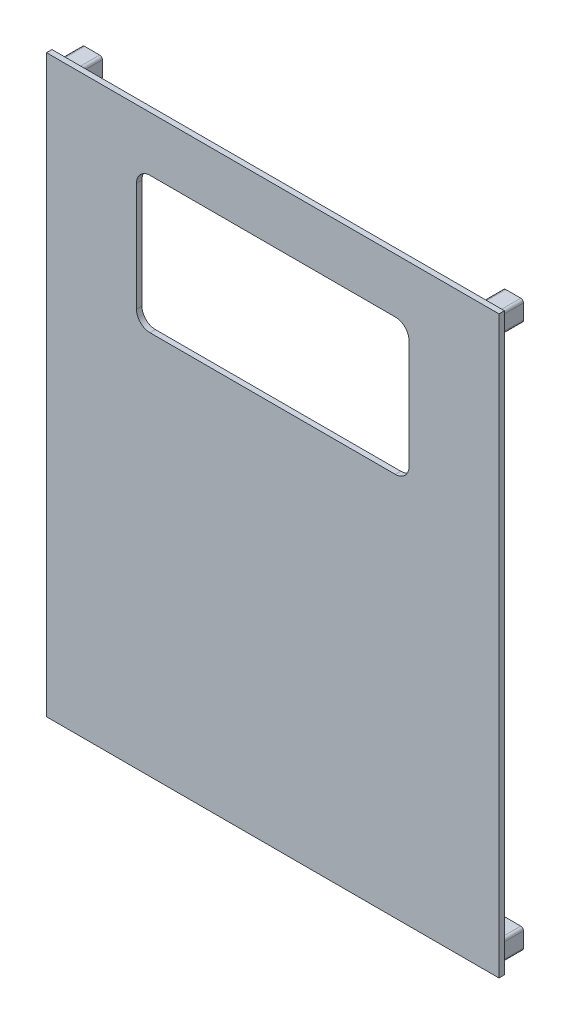
from build123d import *

# Parameters (mm, degrees)
BOSS_EXTRUDE1_DEPTH = 3
SKETCH2_W           = 166
SKETCH2_H           = 211.014567036
SKETCH2_W_2         = 100
SKETCH2_H_2         = 50
BOSS_EXTRUDE2_DEPTH = 3
CUT_EXTRUDE1_DEPTH  = 3
FILLET1_R           = 5
SKETCH4_W           = 7.5
SKETCH4_H           = 7.5
BOSS_EXTRUDE3_DEPTH = 11
FILLET2_R           = 1
SKETCH5_R           = 1.6
CUT_EXTRUDE2_DEPTH  = 5
SKETCH6_R           = 2.25
CUT_EXTRUDE3_DEPTH  = 3
SKETCH7_W           = 166
SKETCH7_H           = 211.014567036
CUT_EXTRUDE4_DEPTH  = 1


with BuildPart() as part:
    # Sketch1 → Boss-Extrude1 (new body)
    with BuildSketch(Plane.XY):
        with BuildLine():
            Line((48, 73.257283518), (48, -16.742716482))
            ThreePointArc((48, -16.742716482), (50.050252532, -21.69246395), (55, -23.742716482))
            Line((55, -23.742716482), (105, -23.742716482))
            ThreePointArc((105, -23.742716482), (109.949747468, -21.69246395), (112, -16.742716482))
            Line((112, -16.742716482), (112, 73.257283518))
            ThreePointArc((112, 73.257283518), (109.949747468, 78.207030987), (105, 80.257283518))
            Line((105, 80.257283518), (55, 80.257283518))
            ThreePointArc((55, 80.257283518), (50.050252532, 78.207030987), (48, 73.257283518))
        make_face()
        with BuildLine():
            Line((53, 73.257283518), (53, -16.742716482))
            ThreePointArc((53, -16.742716482), (53.585786438, -18.156930044), (55, -18.742716482))
            Line((55, -18.742716482), (105, -18.742716482))
            ThreePointArc((105, -18.742716482), (106.414213562, -18.156930044), (107, -16.742716482))
            Line((107, -16.742716482), (107, 73.257283518))
            ThreePointArc((107, 73.257283518), (106.414213562, 74.671497081), (105, 75.257283518))
            Line((105, 75.257283518), (55, 75.257283518))
            ThreePointArc((55, 75.257283518), (53.585786438, 74.671497081), (53, 73.257283518))
        make_face(mode=Mode.SUBTRACT)
    extrude(amount=-BOSS_EXTRUDE1_DEPTH)

    # Sketch2 → Boss-Extrude2 (add)
    with BuildSketch(Plane.XY):
        with Locations((80, -22.25)):
            Rectangle(SKETCH2_W, SKETCH2_H)
        with Locations((80, 38.257283518)):
            Rectangle(SKETCH2_W_2, SKETCH2_H_2, mode=Mode.SUBTRACT)
    extrude(amount=BOSS_EXTRUDE2_DEPTH)

    # Sketch3 → Cut-Extrude1 (cut)
    with BuildSketch(Plane(origin=(0, 0, -3), x_dir=(-1, 0, 0), z_dir=(0, 0, -1))):
        with BuildLine():
            Line((-55, 80.257283518), (-105, 80.257283518))
            ThreePointArc((-105, 80.257283518), (-109.949747468, 78.207030987), (-112, 73.257283518))
            Line((-112, 73.257283518), (-112, -16.742716482))
            ThreePointArc((-112, -16.742716482), (-109.949747468, -21.69246395), (-105, -23.742716482))
            Line((-105, -23.742716482), (-55, -23.742716482))
            ThreePointArc((-55, -23.742716482), (-50.050252532, -21.69246395), (-48, -16.742716482))
            Line((-48, -16.742716482), (-48, 73.257283518))
            ThreePointArc((-48, 73.257283518), (-50.050252532, 78.207030987), (-55, 80.257283518))
        make_face()
    extrude(amount=-CUT_EXTRUDE1_DEPTH, mode=Mode.SUBTRACT)

    # Fillet1
    fillet1_edges = [part.edges().sort_by_distance(p)[0] for p in [
        (30, 13.257283518, 1.5),
        (130, 13.257283518, 1.5),
        (130, 63.257283518, 1.5),
        (30, 63.257283518, 1.5),
    ]]
    fillet(fillet1_edges, radius=FILLET1_R)

    # Sketch4 → Boss-Extrude3 (add)
    with BuildSketch(Plane.XY.offset(3)):
        with Locations((2.75, 77.507283518)):
            Rectangle(SKETCH4_W, SKETCH4_H)
        with Locations((157.25, -122.007283518)):
            Rectangle(SKETCH4_W, SKETCH4_H)
        with Locations((2.75, -122.007283518)):
            Rectangle(SKETCH4_W, SKETCH4_H)
        with Locations((157.25, 77.507283518)):
            Rectangle(SKETCH4_W, SKETCH4_H)
    extrude(amount=-BOSS_EXTRUDE3_DEPTH)

    # Fillet2
    fillet2_edges = [part.edges().sort_by_distance(p)[0] for p in [
        (-1, 73.757283518, -4),
        (-1, 81.257283518, -4),
        (6.5, 81.257283518, -4),
        (6.5, 73.757283518, -4),
        (161, -118.257283518, -4),
        (161, -125.757283518, -4),
        (153.5, -125.757283518, -4),
        (153.5, -118.257283518, -4),
        (-1, -125.757283518, -4),
        (-1, -118.257283518, -4),
        (6.5, -118.257283518, -4),
        (6.5, -125.757283518, -4),
        (161, 81.257283518, -4),
        (161, 73.757283518, -4),
        (153.5, 73.757283518, -4),
        (153.5, 81.257283518, -4),
    ]]
    fillet(fillet2_edges, radius=FILLET2_R)

    # Sketch5 → Cut-Extrude2 (cut)
    with BuildSketch(Plane(origin=(0, 0, -8), x_dir=(-1, 0, 0), z_dir=(0, 0, -1))):
        with Locations((-157.25, 77.507283518)):
            Circle(SKETCH5_R)
        with Locations((-2.75, 77.507283518)):
            Circle(SKETCH5_R)
        with Locations((-2.75, -122.007283518)):
            Circle(SKETCH5_R)
        with Locations((-157.25, -122.007283518)):
            Circle(SKETCH5_R)
    extrude(amount=-CUT_EXTRUDE2_DEPTH, mode=Mode.SUBTRACT)

    # Sketch6 → Cut-Extrude3 (cut)
    with BuildSketch(Plane(origin=(0, 0, -8), x_dir=(-1, 0, 0), z_dir=(0, 0, -1))):
        with Locations((-157.25, 77.507283518)):
            Circle(SKETCH6_R)
        with Locations((-2.75, 77.507283518)):
            Circle(SKETCH6_R)
        with Locations((-157.25, -122.007283518)):
            Circle(SKETCH6_R)
        with Locations((-2.75, -122.007283518)):
            Circle(SKETCH6_R)
    extrude(amount=-CUT_EXTRUDE3_DEPTH, mode=Mode.SUBTRACT)

    # Sketch7 → Cut-Extrude4 (cut)
    with BuildSketch(Plane(origin=(0, 0, 0), x_dir=(-1, 0, 0), z_dir=(0, 0, -1))):
        with Locations((-80, -22.25)):
            Rectangle(SKETCH7_W, SKETCH7_H)
        with BuildLine():
            Line((-160, 73.757283518), (-154.5, 73.757283518))
            ThreePointArc((-154.5, 73.757283518), (-153.792893219, 74.050176737), (-153.5, 74.757283518))
            Line((-153.5, 74.757283518), (-153.5, 80.257283518))
            ThreePointArc((-153.5, 80.257283518), (-153.792893219, 80.9643903), (-154.5, 81.257283518))
            Line((-154.5, 81.257283518), (-160, 81.257283518))
            ThreePointArc((-160, 81.257283518), (-160.707106781, 80.9643903), (-161, 80.257283518))
            Line((-161, 80.257283518), (-161, 74.757283518))
            ThreePointArc((-161, 74.757283518), (-160.707106781, 74.050176737), (-160, 73.757283518))
        make_face(mode=Mode.SUBTRACT)
        with BuildLine():
            Line((-5.5, 73.757283518), (0, 73.757283518))
            ThreePointArc((0, 73.757283518), (0.707106781, 74.050176737), (1, 74.757283518))
            Line((1, 74.757283518), (1, 80.257283518))
            ThreePointArc((1, 80.257283518), (0.707106781, 80.9643903), (0, 81.257283518))
            Line((0, 81.257283518), (-5.5, 81.257283518))
            ThreePointArc((-5.5, 81.257283518), (-6.207106781, 80.9643903), (-6.5, 80.257283518))
            Line((-6.5, 80.257283518), (-6.5, 74.757283518))
            ThreePointArc((-6.5, 74.757283518), (-6.207106781, 74.050176737), (-5.5, 73.757283518))
        make_face(mode=Mode.SUBTRACT)
        with BuildLine():
            Line((-154.5, -118.257283518), (-160, -118.257283518))
            ThreePointArc((-160, -118.257283518), (-160.707106781, -118.550176737), (-161, -119.257283518))
            Line((-161, -119.257283518), (-161, -124.757283518))
            ThreePointArc((-161, -124.757283518), (-160.707106781, -125.464390299), (-160, -125.757283518))
            Line((-160, -125.757283518), (-154.5, -125.757283518))
            ThreePointArc((-154.5, -125.757283518), (-153.792893219, -125.464390299), (-153.5, -124.757283518))
            Line((-153.5, -124.757283518), (-153.5, -119.257283518))
            ThreePointArc((-153.5, -119.257283518), (-153.792893219, -118.550176737), (-154.5, -118.257283518))
        make_face(mode=Mode.SUBTRACT)
        with BuildLine():
            Line((-6.5, -119.257283518), (-6.5, -124.757283518))
            ThreePointArc((-6.5, -124.757283518), (-6.207106781, -125.464390299), (-5.5, -125.757283518))
            Line((-5.5, -125.757283518), (0, -125.757283518))
            ThreePointArc((0, -125.757283518), (0.707106781, -125.464390299), (1, -124.757283518))
            Line((1, -124.757283518), (1, -119.257283518))
            ThreePointArc((1, -119.257283518), (0.707106781, -118.550176737), (0, -118.257283518))
            Line((0, -118.257283518), (-5.5, -118.257283518))
            ThreePointArc((-5.5, -118.257283518), (-6.207106781, -118.550176737), (-6.5, -119.257283518))
        make_face(mode=Mode.SUBTRACT)
    extrude(amount=-CUT_EXTRUDE4_DEPTH, mode=Mode.SUBTRACT)


solid = part.part
